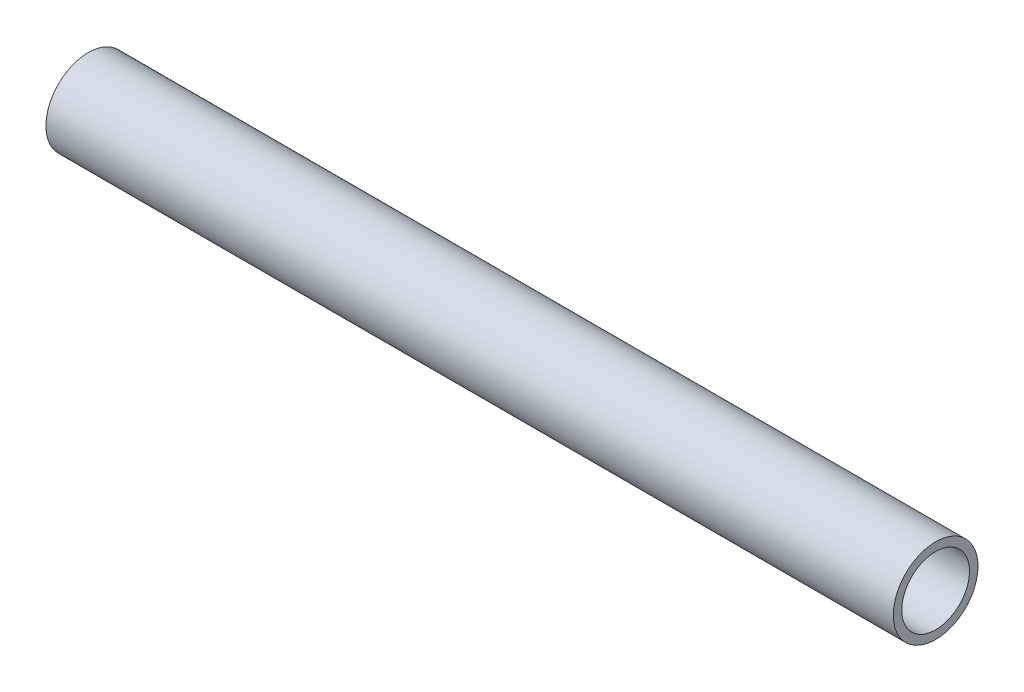
from build123d import *

# Parameters (mm, degrees)
SKETCH11_R            = 12.7
SKETCH11_R_2          = 10.16
TUBING_TUBING_1_DEPTH = 254


with BuildPart() as part:
    # Sketch11 → Tubing TUBING(1) (new body)
    with BuildSketch(Plane.YZ):
        Circle(SKETCH11_R)
        Circle(SKETCH11_R_2, mode=Mode.SUBTRACT)
    extrude(amount=TUBING_TUBING_1_DEPTH)


solid = part.part
